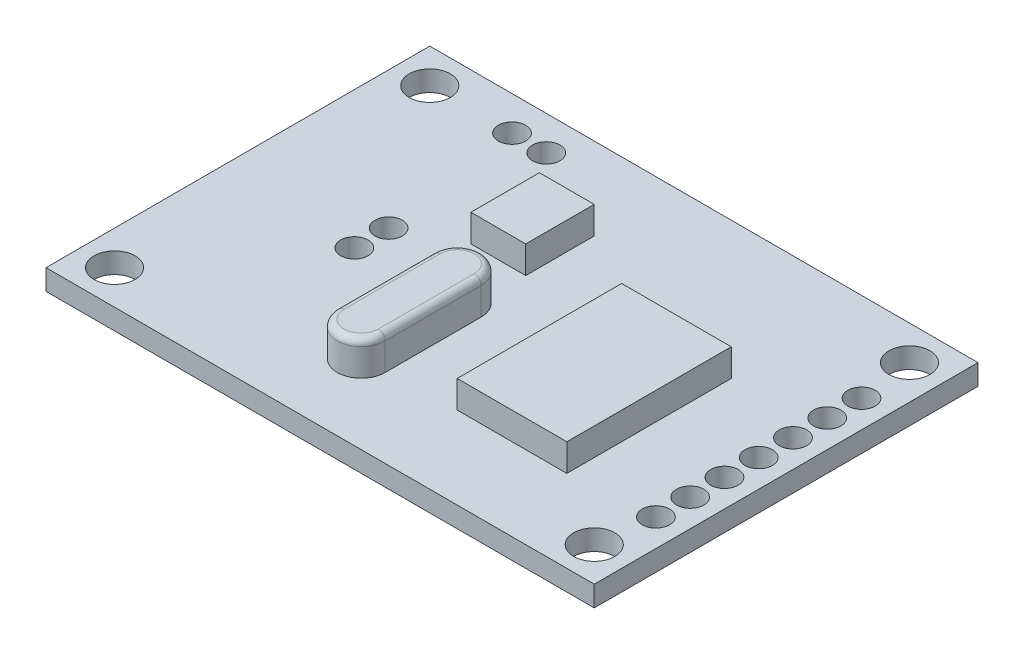
from build123d import *

# Parameters (mm, degrees)
SKETCH1_W           = 40
SKETCH1_H           = 28
SKETCH1_R           = 1.5
BOSS_EXTRUDE1_DEPTH = 1.5
SKETCH2_R           = 1
CUT_EXTRUDE1_DEPTH  = 2.5
SKETCH3_W           = 8
SKETCH3_H           = 12
BOSS_EXTRUDE2_DEPTH = 2
SKETCH4_W           = 4
SKETCH4_H           = 5
BOSS_EXTRUDE3_DEPTH = 2
SKETCH5_R           = 1
CUT_EXTRUDE2_DEPTH  = 2.5
BOSS_EXTRUDE4_DEPTH = 2.5
FILLET1_R           = 0.5


with BuildPart() as part:
    # Sketch1 → Boss-Extrude1 (new body)
    with BuildSketch(Plane(origin=(0, 0, 0), x_dir=(1, 0, 0), z_dir=(0, 1, 0))):
        with Locations((20, 14)):
            Rectangle(SKETCH1_W, SKETCH1_H)
        with Locations((2.5, 25.5)):
            Circle(SKETCH1_R, mode=Mode.SUBTRACT)
        with Locations((2.5, 2.5)):
            Circle(SKETCH1_R, mode=Mode.SUBTRACT)
        with Locations((37.5, 25.5)):
            Circle(SKETCH1_R, mode=Mode.SUBTRACT)
        with Locations((37.5, 2.5)):
            Circle(SKETCH1_R, mode=Mode.SUBTRACT)
    extrude(amount=BOSS_EXTRUDE1_DEPTH)

    # Sketch2 → Cut-Extrude1 (cut, through all)
    with BuildSketch(Plane(origin=(0, 1.5, 0), x_dir=(1, 0, 0), z_dir=(0, 1, 0))):
        with Locations((38, 6.5)):
            Circle(SKETCH2_R)
        with Locations((38, 9)):
            Circle(SKETCH2_R)
        with Locations((38, 11.5)):
            Circle(SKETCH2_R)
        with Locations((38, 14)):
            Circle(SKETCH2_R)
        with Locations((38, 16.5)):
            Circle(SKETCH2_R)
        with Locations((38, 19)):
            Circle(SKETCH2_R)
        with Locations((38, 21.5)):
            Circle(SKETCH2_R)
    extrude(amount=-CUT_EXTRUDE1_DEPTH, mode=Mode.SUBTRACT)

    # Sketch3 → Boss-Extrude2 (add)
    with BuildSketch(Plane(origin=(0, 1.5, 0), x_dir=(1, 0, 0), z_dir=(0, 1, 0))):
        with Locations((28, 12)):
            Rectangle(SKETCH3_W, SKETCH3_H)
    extrude(amount=BOSS_EXTRUDE2_DEPTH)

    # Sketch4 → Boss-Extrude3 (add)
    with BuildSketch(Plane(origin=(0, 1.5, 0), x_dir=(1, 0, 0), z_dir=(0, 1, 0))):
        with Locations((16, 19.5)):
            Rectangle(SKETCH4_W, SKETCH4_H)
    extrude(amount=BOSS_EXTRUDE3_DEPTH)

    # Sketch5 → Cut-Extrude2 (cut, through all)
    with BuildSketch(Plane(origin=(0, 1.5, 0), x_dir=(1, 0, 0), z_dir=(0, 1, 0))):
        with Locations((10, 15)):
            Circle(SKETCH5_R)
        with Locations((10, 12.5)):
            Circle(SKETCH5_R)
        with Locations((8.5, 25.5)):
            Circle(SKETCH5_R)
        with Locations((11, 25.5)):
            Circle(SKETCH5_R)
    extrude(amount=-CUT_EXTRUDE2_DEPTH, mode=Mode.SUBTRACT)

    # Sketch6 → Boss-Extrude4 (add)
    with BuildSketch(Plane(origin=(0, 1.5, 0), x_dir=(1, 0, 0), z_dir=(0, 1, 0))):
        with BuildLine():
            Line((19, 12.75), (19, 5.75))
            ThreePointArc((19, 5.75), (17.25, 4), (15.5, 5.75))
            Line((15.5, 5.75), (15.5, 12.75))
            ThreePointArc((15.5, 12.75), (17.25, 14.5), (19, 12.75))
        make_face()
    extrude(amount=BOSS_EXTRUDE4_DEPTH)

    # Fillet1
    fillet1_edges = [part.edges().sort_by_distance(p)[0] for p in [
        (17.25, 4, -14.5),
        (15.5, 4, -9.25),
        (17.25, 4, -4),
        (19, 4, -9.25),
    ]]
    fillet(fillet1_edges, radius=FILLET1_R)


solid = part.part
